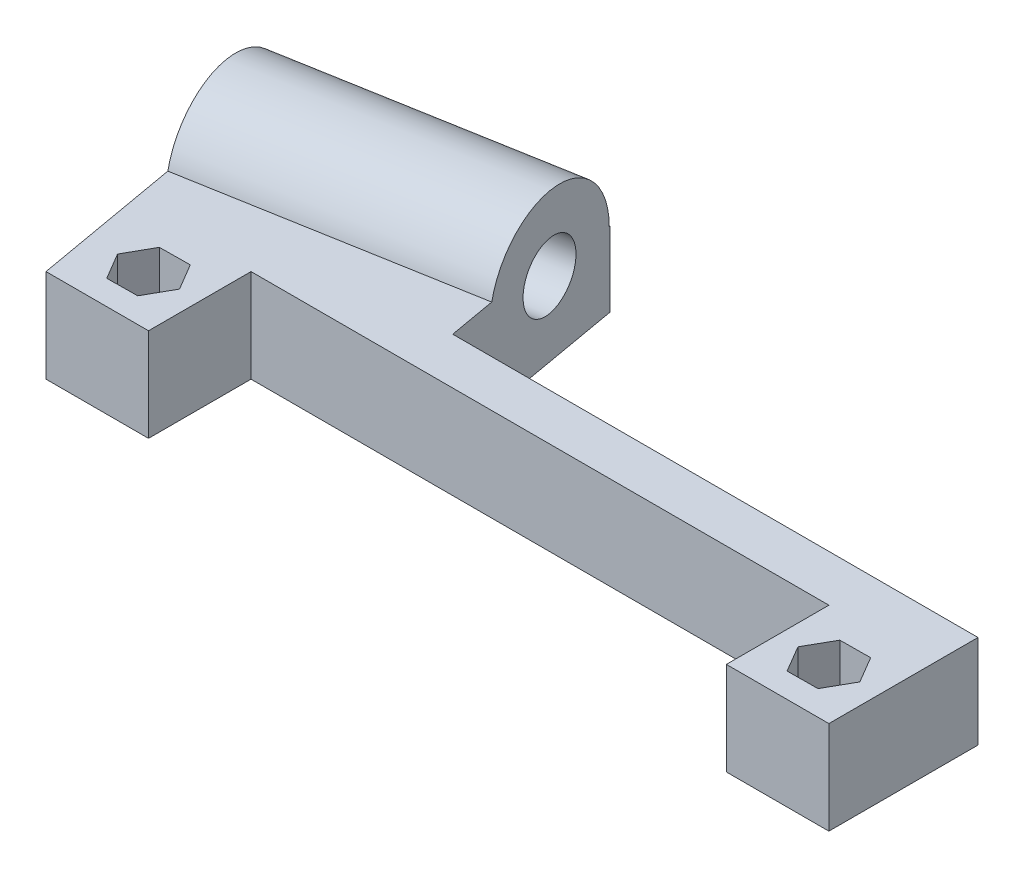
from build123d import *

# Parameters (mm, degrees)
EXTRUDE_1_DEPTH          = 10
SKETCH_2_R               = 1.5
CUT_EXTRUDE_1_DEPTH      = 10
CUT_EXTRUDE_2_DEPTH      = 6
EXTRUDE_2_DEPTH          = 16
CUT_EXTRUDE_3_DEPTH      = 60.059147092
CUT_EXTRUDE_3_DEPTH_BACK = 36.4308247
SKETCH_6_R               = 3.5
CUT_EXTRUDE_4_DEPTH      = 36.4308247
SKETCH_8_R               = 5.25
CUT_EXTRUDE_6_DEPTH      = 24


with BuildPart() as part:
    # 草图1 → 凸台-拉伸1 (new body)
    with BuildSketch(Plane(origin=(0, 0, 0), x_dir=(1, 0, 0), z_dir=(0, 1, 0))):
        Polygon((-42, 5.5), (-42, 10.5), (42, 10.5), (42, 5.5), (42, -5.5), (31, -5.5), (31, 5.5), (-31, 5.5), (-31, -5.5), (-42, -5.5), align=None)
    extrude(amount=EXTRUDE_1_DEPTH)

    # 草图2 → 切除-拉伸1 (cut)
    with BuildSketch(Plane(origin=(0, 10, 0), x_dir=(1, 0, 0), z_dir=(0, 1, 0))):
        with Locations((-36.5, 0)):
            Circle(SKETCH_2_R)
        with Locations((36.5, 0)):
            Circle(SKETCH_2_R)
    extrude(amount=-CUT_EXTRUDE_1_DEPTH, mode=Mode.SUBTRACT)

    # 草图3 → 切除-拉伸2 (cut)
    with BuildSketch(Plane(origin=(0, 10, 0), x_dir=(1, 0, 0), z_dir=(0, 1, 0))):
        Polygon((-34.826211876, -2.833449014), (-33.209267111, 0.032818529), (-34.883055236, 2.866267543), (-38.173788124, 2.833449014), (-39.790732889, -0.032818529), (-38.116944764, -2.866267543), align=None)
        Polygon((38.168661206, -2.836471361), (39.790786858, 0.026867314), (38.122125653, 2.863338675), (34.831338794, 2.836471361), (33.209213142, -0.026867314), (34.877874347, -2.863338675), align=None)
    extrude(amount=-CUT_EXTRUDE_2_DEPTH, mode=Mode.SUBTRACT)

    # 草图4 → 凸台-拉伸2 (add)
    with BuildSketch(Plane(origin=(0, 0, 0), x_dir=(1, 0, 0), z_dir=(0, 1, 0))):
        Polygon((-44.778370843, 26.256924048), (-47.514531989, 25.774465014), (-42, -5.5), (-42, 10.5), (-14.358361399, 10.5), (-17.970229632, 30.983922646), align=None)
    extrude(amount=EXTRUDE_2_DEPTH)

    # 草图5 → 切除-拉伸3 (cut, two sides)
    with BuildSketch(Plane(origin=(-12.129798074, 0, 2.138810671), x_dir=(-0.173648178, 0, -0.984807753), z_dir=(0.984807753, 0, -0.173648178))) as cut_extrude_3_sk:
        with BuildLine():
            Line((33.533704869, 8), (33.633704869, 8))
            Line((33.633704869, 8), (33.633704869, 16))
            Line((33.633704869, 16), (1.87678082, 16))
            Line((1.87678082, 16), (1.87678082, 10))
            Line((1.87678082, 10), (12.833784698, 10))
            Line((12.833784698, 10), (17.991061347, 10))
            ThreePointArc((17.991061347, 10), (26.641949923, 15.83539673), (33.533704869, 8))
        make_face()
    extrude(amount=CUT_EXTRUDE_3_DEPTH, mode=Mode.SUBTRACT)
    extrude(cut_extrude_3_sk.sketch, amount=-CUT_EXTRUDE_3_DEPTH_BACK, mode=Mode.SUBTRACT)

    # 草图6 → 切除-拉伸4 (cut, through all)
    with BuildSketch(Plane(origin=(-12.129798074, 0, 2.138810671), x_dir=(-0.173648178, 0, -0.984807753), z_dir=(0.984807753, 0, -0.173648178))):
        with Locations((25.633704869, 8)):
            Circle(SKETCH_6_R)
    extrude(amount=-CUT_EXTRUDE_4_DEPTH, mode=Mode.SUBTRACT)

    # 草图8 → 切除-拉伸6 (cut)
    with BuildSketch(Plane(origin=(-41.674100431, 0, 7.348268303), x_dir=(0.173648178, 0, 0.984807753), z_dir=(-0.984807753, 0, 0.173648178))):
        with Locations((-25.633704869, 8)):
            Circle(SKETCH_8_R)
    extrude(amount=-CUT_EXTRUDE_6_DEPTH, mode=Mode.SUBTRACT)


solid = part.part
